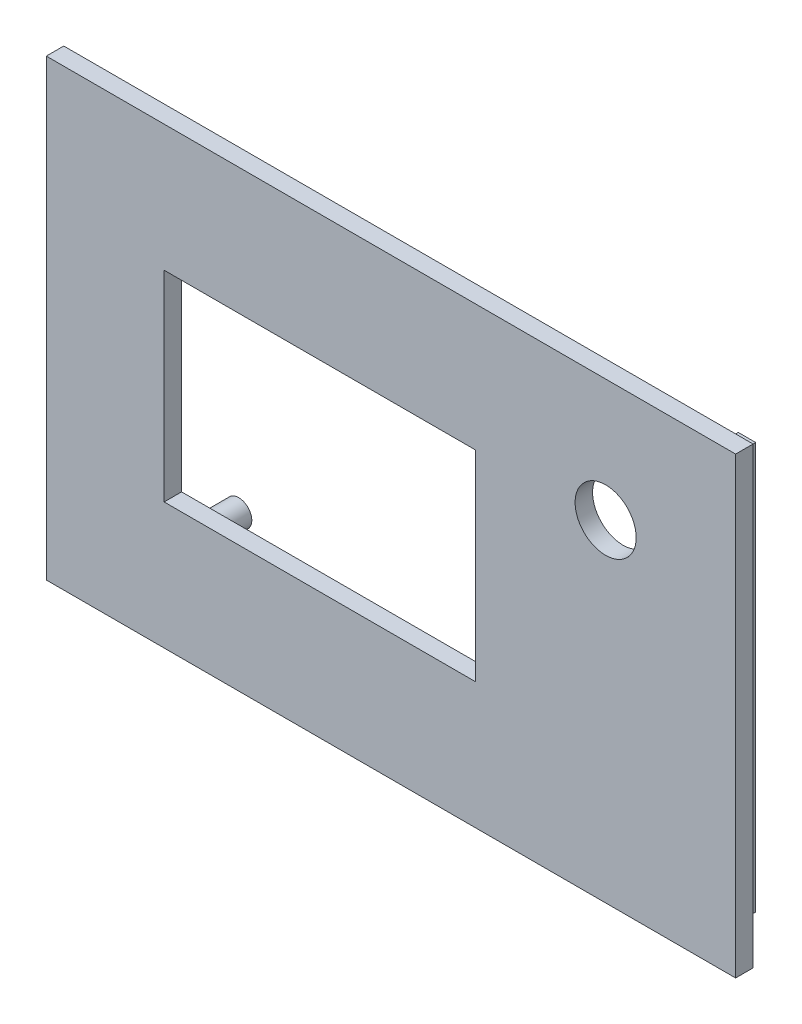
from build123d import *

# Parameters (mm, degrees)
SKIZZE10_W                       = 79
SKIZZE10_H                       = 52
AUFSATZ_LINEAR_AUSTRAGEN8_DEPTH  = 2
SKIZZE11_W                       = 35.7
SKIZZE11_H                       = 23
SCHNITT_LINEAR_AUSTRAGEN3_DEPTH  = 2
SKIZZE13_R                       = 3.5
SCHNITT_LINEAR_AUSTRAGEN4_DEPTH  = 2
SKIZZE14_R                       = 1.5
AUFSATZ_LINEAR_AUSTRAGEN9_DEPTH  = 4
AUFSATZ_LINEAR_AUSTRAGEN10_DEPTH = 3


with BuildPart() as part:
    # Skizze10 → Aufsatz-Linear austragen8 (new body)
    with BuildSketch(Plane.XY):
        with Locations((-19.990421456, -28.402298851)):
            Rectangle(SKIZZE10_W, SKIZZE10_H)
    extrude(amount=AUFSATZ_LINEAR_AUSTRAGEN8_DEPTH)

    # Skizze11 → Schnitt-Linear austragen3 (cut)
    with BuildSketch(Plane.XY.offset(2)):
        with Locations((-28.136972684, -28.402298851)):
            Rectangle(SKIZZE11_W, SKIZZE11_H)
    extrude(amount=-SCHNITT_LINEAR_AUSTRAGEN3_DEPTH, mode=Mode.SUBTRACT)

    # Skizze13 → Schnitt-Linear austragen4 (cut)
    with BuildSketch(Plane.XY.offset(2)):
        with Locations((4.61130293, -16.402298851)):
            Circle(SKIZZE13_R)
    extrude(amount=-SCHNITT_LINEAR_AUSTRAGEN4_DEPTH, mode=Mode.SUBTRACT)

    # Skizze14 → Aufsatz-Linear austragen9 (add)
    with BuildSketch(Plane(origin=(0, 0, 0), x_dir=(-1, 0, 0), z_dir=(0, 0, -1))):
        with Locations((43.436972684, -14.102298851)):
            Circle(SKIZZE14_R)
        with Locations((43.436972684, -42.702298851)):
            Circle(SKIZZE14_R)
        with Locations((12.836972684, -14.102298851)):
            Circle(SKIZZE14_R)
        with Locations((12.836972684, -42.702298851)):
            Circle(SKIZZE14_R)
    extrude(amount=AUFSATZ_LINEAR_AUSTRAGEN9_DEPTH)

    # Skizze15 → Aufsatz-Linear austragen10 (add)
    with BuildSketch(Plane(origin=(0, 0, 0), x_dir=(-1, 0, 0), z_dir=(0, 0, -1))):
        Polygon((-16.809578544, -5.102298851), (-16.809578544, -51.702298851), (56.790421456, -51.702298851), (56.790421456, -49.702298851), (-14.809578544, -49.702298851), (-14.809578544, -5.102298851), align=None)
    extrude(amount=AUFSATZ_LINEAR_AUSTRAGEN10_DEPTH)


solid = part.part
